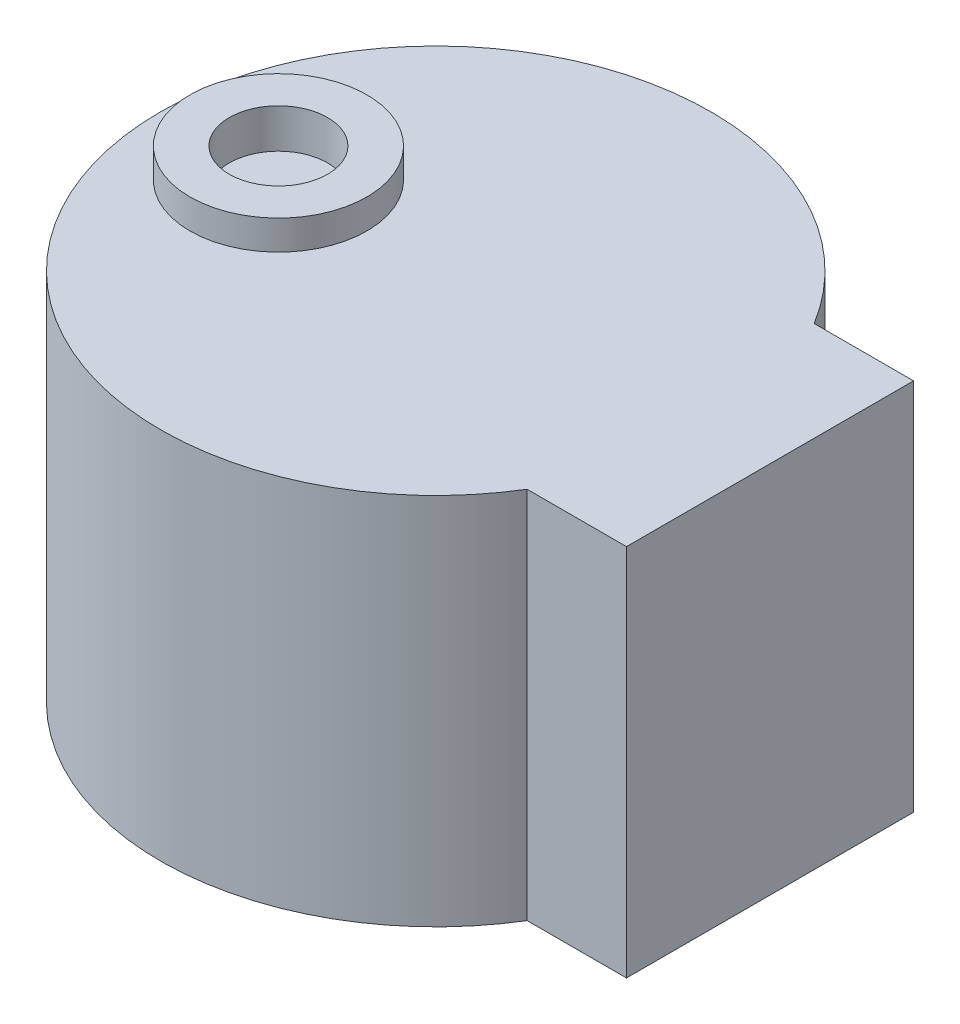
from build123d import *

# Parameters (mm, degrees)
CROQUIS1_R                 = 14
CROQUIS1_W                 = 14.155779923
CROQUIS1_H                 = 14.6
SALIENTE_EXTRUIR1_DEPTH    = 19
CROQUIS2_R                 = 4.5
SALIENTE_EXTRUIR2_DEPTH    = 1.5
CROQUIS3_R                 = 2.5
SALIENTE_EXTRUIR3_DEPTH    = 2.5
SALIENTE_EXTRUIR4_DEPTH    = 6
CROQUIS5_R                 = 2.5
CORTAR_EXTRUIR1_DEPTH      = 10
CORTAR_EXTRUIR1_DEPTH_BACK = 2


with BuildPart() as part:
    # Croquis1 → Saliente-Extruir1 (new body)
    with BuildSketch(Plane(origin=(0, 0, 0), x_dir=(1, 0, 0), z_dir=(0, 1, 0))):
        Circle(CROQUIS1_R)
        with Locations((9.922110038, 0)):
            Rectangle(CROQUIS1_W, CROQUIS1_H)
    extrude(amount=SALIENTE_EXTRUIR1_DEPTH)

    # Croquis2 → Saliente-Extruir2 (add)
    with BuildSketch(Plane(origin=(0, 19, 0), x_dir=(1, 0, 0), z_dir=(0, 1, 0))):
        with Locations((-8, 0)):
            Circle(CROQUIS2_R)
    extrude(amount=SALIENTE_EXTRUIR2_DEPTH)

    # Croquis3 → Saliente-Extruir3 (add)
    with BuildSketch(Plane(origin=(0, 20.5, 0), x_dir=(1, 0, 0), z_dir=(0, 1, 0))):
        with Locations((-8, 0)):
            Circle(CROQUIS3_R)
    extrude(amount=SALIENTE_EXTRUIR3_DEPTH)

    # Croquis4 → Saliente-Extruir4 (add)
    with BuildSketch(Plane(origin=(0, 23, 0), x_dir=(1, 0, 0), z_dir=(0, 1, 0))):
        with BuildLine():
            Line((-9.5, 2), (-9.5, -2))
            ThreePointArc((-9.5, -2), (-8, -2.5), (-6.5, -2))
            Line((-6.5, -2), (-6.5, 2))
            ThreePointArc((-6.5, 2), (-8, 2.5), (-9.5, 2))
        make_face()
    extrude(amount=SALIENTE_EXTRUIR4_DEPTH)

    # Croquis5 → Cortar-Extruir1 (cut, two sides)
    with BuildSketch(Plane(origin=(0, 20.5, 0), x_dir=(1, 0, 0), z_dir=(0, 1, 0))) as cortar_extruir1_sk:
        with Locations((-8, 0)):
            Circle(CROQUIS5_R)
    extrude(amount=CORTAR_EXTRUIR1_DEPTH, mode=Mode.SUBTRACT)
    extrude(cortar_extruir1_sk.sketch, amount=-CORTAR_EXTRUIR1_DEPTH_BACK, mode=Mode.SUBTRACT)


solid = part.part
